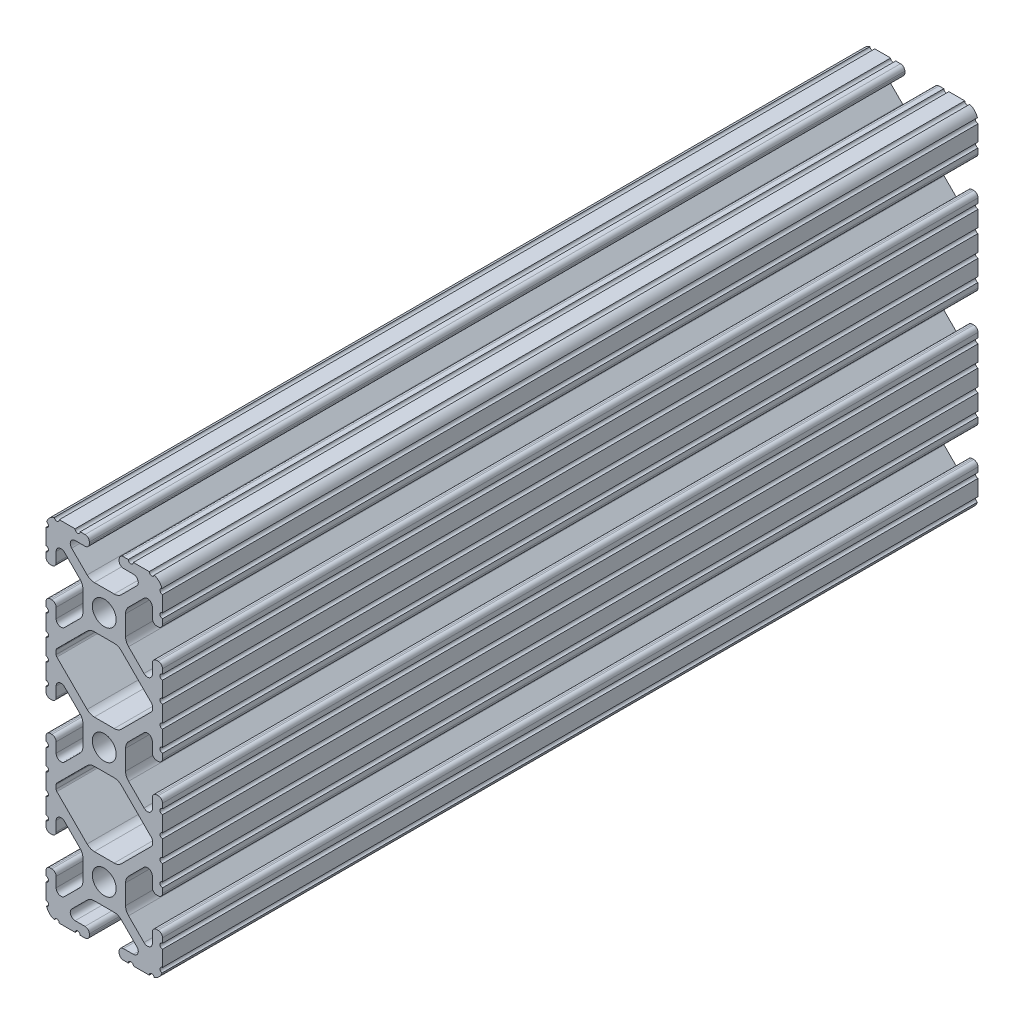
from build123d import *

# Parameters (mm, degrees)
BOSS_EXTRUDE1_DEPTH     = 88.9
SKETCH5_R               = 0.55245
CUT_EXTRUDE1_DEPTH      = 98.550550998
CUT_EXTRUDE1_DEPTH_BACK = 98.550550998
BOSS_EXTRUDE2_DEPTH     = 88.9
CUT_EXTRUDE2_DEPTH      = 98.550550998
CUT_EXTRUDE2_DEPTH_BACK = 98.550550998


with BuildPart() as part:
    # Sketch4 → Boss-Extrude1 (new, symmetric)
    with BuildSketch(Plane.XY):
        with BuildLine():
            Line((4.190365, -38.1), (10.11729625, -38.1))
            ThreePointArc((10.11729625, -38.1), (11.943543585, -37.343543585), (12.7, -35.51729625))
            Line((12.7, -35.51729625), (12.7, -29.590365))
            ThreePointArc((12.7, -29.590365), (12.42492494, -28.92627506), (11.760835, -28.6512))
            Line((11.760835, -28.6512), (11.429365, -28.6512))
            ThreePointArc((11.429365, -28.6512), (10.76527506, -28.92627506), (10.4902, -29.590365))
            Line((10.4902, -29.590365), (10.4902, -31.748478019))
            ThreePointArc((10.4902, -31.748478019), (9.830707141, -32.735478831), (8.666460301, -32.503895736))
            Line((8.666460301, -32.503895736), (5.299899128, -29.137334563))
            ThreePointArc((5.299899128, -29.137334563), (4.817571085, -28.415479634), (4.6482, -27.56399369))
            Line((4.6482, -27.56399369), (4.6482, -25.4))
            Line((4.6482, -25.4), (2.6035, -25.4))
            ThreePointArc((2.6035, -25.4), (1.840952505, -27.240952505), (0, -28.0035))
            Line((0, -28.0035), (0, -30.0482))
            Line((0, -30.0482), (2.16399369, -30.0482))
            ThreePointArc((2.16399369, -30.0482), (3.015479634, -30.217571085), (3.737334563, -30.699899128))
            Line((3.737334563, -30.699899128), (7.103895736, -34.066460301))
            ThreePointArc((7.103895736, -34.066460301), (7.335478831, -35.230707141), (6.348478019, -35.8902))
            Line((6.348478019, -35.8902), (4.190365, -35.8902))
            ThreePointArc((4.190365, -35.8902), (3.52627506, -36.16527506), (3.2512, -36.829365))
            Line((3.2512, -36.829365), (3.2512, -37.160835))
            ThreePointArc((3.2512, -37.160835), (3.52627506, -37.82492494), (4.190365, -38.1))
        make_face()
    extrude(amount=BOSS_EXTRUDE1_DEPTH, both=True)

    # Sketch5 → Cut-Extrude1 (cut, two sides)
    with BuildSketch(Plane.XY) as cut_extrude1_sk:
        with Locations((10.356153152, -38.1)):
            Circle(SKETCH5_R)
        with Locations((5.796028019, -38.1)):
            Circle(SKETCH5_R)
        with Locations((12.7, -35.756153152)):
            Circle(SKETCH5_R)
        with Locations((12.7, -31.196028019)):
            Circle(SKETCH5_R)
    extrude(amount=CUT_EXTRUDE1_DEPTH, mode=Mode.SUBTRACT)
    extrude(cut_extrude1_sk.sketch, amount=-CUT_EXTRUDE1_DEPTH_BACK, mode=Mode.SUBTRACT)

    # Mirror1: part across plane


with BuildPart() as part_1:
    add(part.part)
    add(part.part.mirror(Plane(origin=(4.6482, -25.4, 88.9), x_dir=(0, 0, 1), z_dir=(0, -1, 0))))

    # Sketch6 → Boss-Extrude2 (add, symmetric)
    with BuildSketch(Plane.XY):
        with BuildLine():
            Line((12.7, -14.491396848), (12.7, -12.7))
            Line((12.7, -12.7), (9.803703152, -12.7))
            Line((9.803703152, -12.7), (9.803703152, -15.596296848))
            Line((9.803703152, -15.596296848), (12.7, -15.596296848))
            ThreePointArc((12.7, -15.596296848), (12.14755, -15.043846848), (12.7, -14.491396848))
        make_face()
    extrude(amount=BOSS_EXTRUDE2_DEPTH, both=True)

    # Sketch7 → Cut-Extrude2 (cut, two sides)
    with BuildSketch(Plane.XY) as cut_extrude2_sk:
        with BuildLine():
            Line((5.420615149, -18.416820286), (10.328391141, -13.509044294))
            ThreePointArc((10.328391141, -13.509044294), (10.448147248, -13.329816615), (10.4902, -13.118403152))
            Line((10.4902, -13.118403152), (10.4902, -12.7))
            Line((10.4902, -12.7), (0, -12.7))
            Line((0, -12.7), (5.420615149, -18.416820286))
        make_face()
    extrude(amount=CUT_EXTRUDE2_DEPTH, mode=Mode.SUBTRACT)
    extrude(cut_extrude2_sk.sketch, amount=-CUT_EXTRUDE2_DEPTH_BACK, mode=Mode.SUBTRACT)

    # Mirror2: part across plane


with BuildPart() as part_2:
    add(part_1.part)
    add(part_1.part.mirror(Plane(origin=(4.190365, -12.7, 88.9), x_dir=(0, 0, 1), z_dir=(0, -1, 0))))

    # SurfaceCut1
    split(bisect_by=Plane(origin=(0, 0, 0), x_dir=(1, 0, 0), z_dir=(0, 1, 0)), keep=Keep.BOTTOM)

    # Mirror3: part across plane


with BuildPart() as part_3:
    add(part_2.part)
    add(part_2.part.mirror(Plane(origin=(0, 0, 0), x_dir=(0, 0, 1), z_dir=(1, 0, 0))))

    # Mirror4: part across plane


with BuildPart() as part_4:
    add(part_3.part)
    add(part_3.part.mirror(Plane.ZX))


solid = part_4.part
